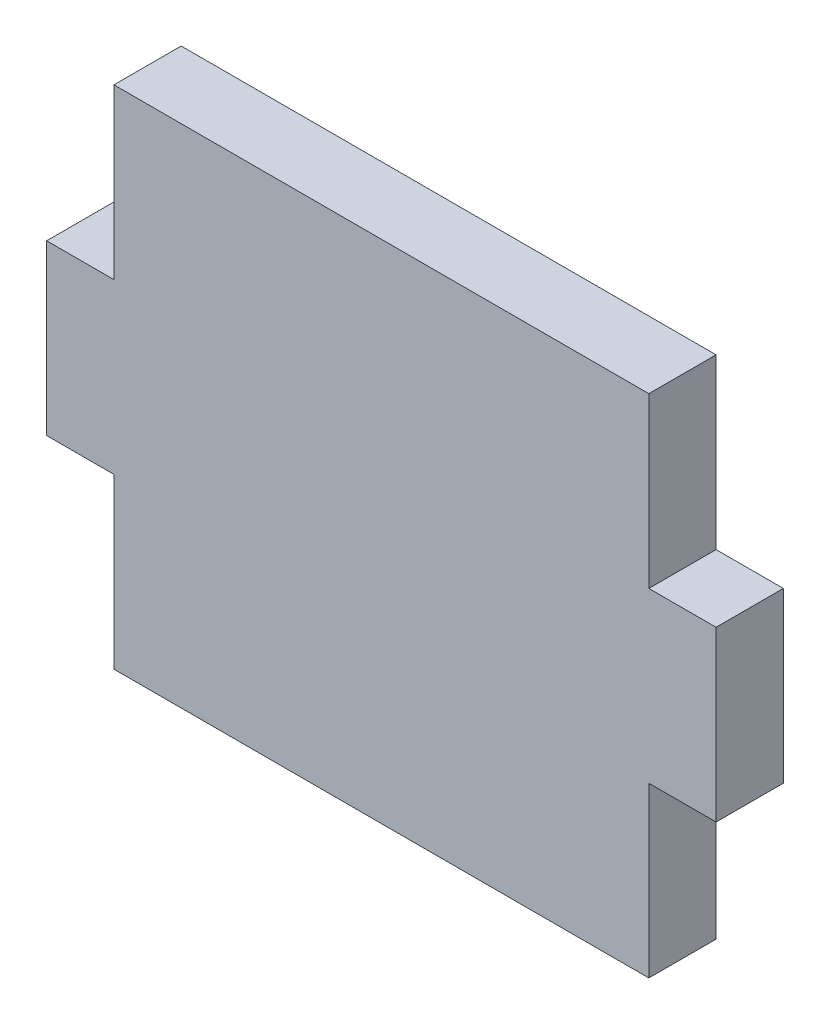
from build123d import *

# Parameters (mm, degrees)
SKETCH1_W           = 53.086
SKETCH1_H           = 40.132
BOSS_EXTRUDE1_DEPTH = 5.334
SKETCH6_W           = 5.334
SKETCH6_H           = 13.377333333
CUT_EXTRUDE2_DEPTH  = 6.334


with BuildPart() as part:
    # Sketch1 → Boss-Extrude1 (new body)
    with BuildSketch(Plane.XY):
        with Locations((26.543, 20.066)):
            Rectangle(SKETCH1_W, SKETCH1_H)
    extrude(amount=BOSS_EXTRUDE1_DEPTH)

    # Sketch6 → Cut-Extrude2 (cut, through all)
    with BuildSketch(Plane.XY.offset(5.334)):
        with Locations((2.667, 33.443333334)):
            Rectangle(SKETCH6_W, SKETCH6_H)
        with Locations((2.667, 6.688666667)):
            Rectangle(SKETCH6_W, SKETCH6_H)
        with Locations((50.419, 6.688666667)):
            Rectangle(SKETCH6_W, SKETCH6_H)
        with Locations((50.419, 33.443333334)):
            Rectangle(SKETCH6_W, SKETCH6_H)
    extrude(amount=-CUT_EXTRUDE2_DEPTH, mode=Mode.SUBTRACT)


solid = part.part
